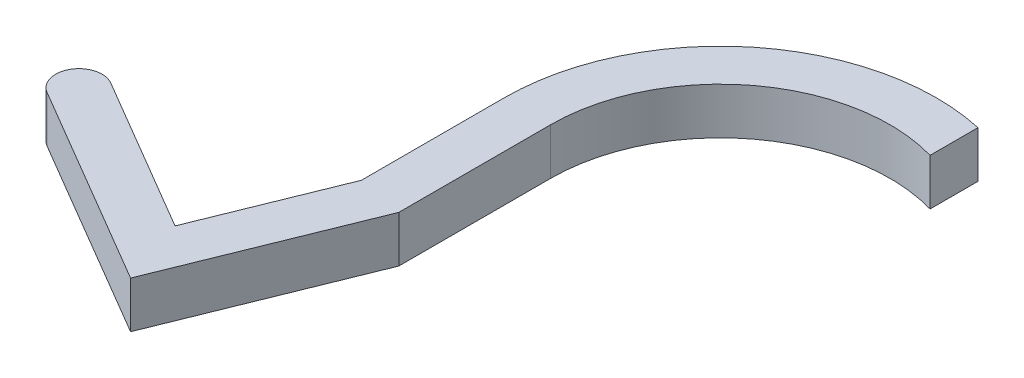
from build123d import *

# Parameters (mm, degrees)
BOSS_EXTRU_1_DEPTH = 10
BOSS_EXTRU_2_DEPTH = 10


with BuildPart() as part:
    # Esquisse1 → Boss.-Extru.1 (new body)
    with BuildSketch(Plane(origin=(0, 0, 0), x_dir=(1, 0, 0), z_dir=(0, 1, 0))):
        with BuildLine():
            Line((10, 45.412002819), (10, 35.103418637))
            ThreePointArc((10, 35.103418637), (-21.991475621, 29.131168875), (-36.5, 0))
            Line((-36.5, 0), (-46.5, 0))
            ThreePointArc((-46.5, 0), (-29.131168875, 36.243965015), (10, 45.412002819))
        make_face()
    extrude(amount=BOSS_EXTRU_1_DEPTH)

    # Esquisse4 → Boss.-Extru.2 (add)
    with BuildSketch(Plane(origin=(0, 10, 0), x_dir=(1, 0, 0), z_dir=(0, 1, 0))):
        with BuildLine():
            Line((-36.5, 0), (-46.5, 0))
            Line((-46.5, 0), (-46.5, -30.702684518))
            Line((-46.5, -30.702684518), (-58.034822919, -59.225728707))
            Line((-58.034822919, -59.225728707), (-91.599603917, -39.502076956))
            ThreePointArc((-91.599603917, -39.502076956), (-98.443575905, -41.279729178), (-96.665923684, -48.123701166))
            Line((-96.665923684, -48.123701166), (-53.109165443, -73.7189324))
            Line((-53.109165443, -73.7189324), (-36.5, -32.648170999))
            Line((-36.5, -32.648170999), (-36.5, 0))
        make_face()
    extrude(amount=-BOSS_EXTRU_2_DEPTH)


solid = part.part
